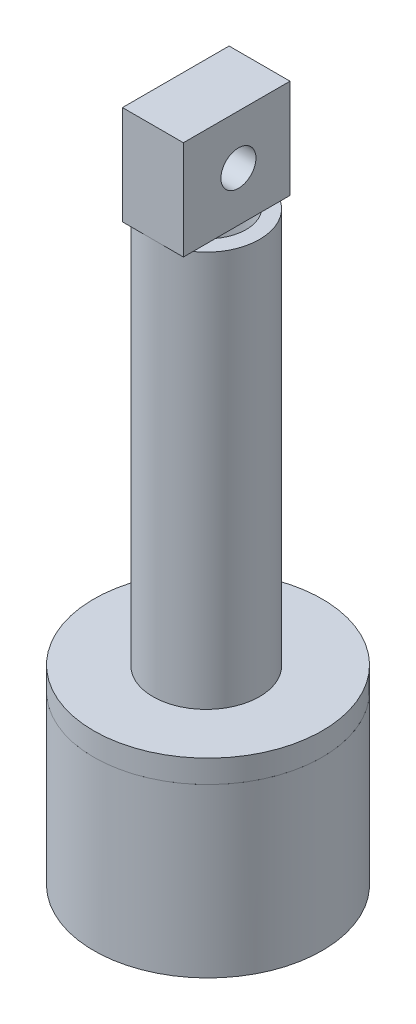
from build123d import *

# Parameters (mm, degrees)
SKETCH1_R           = 15
SKETCH1_R_2         = 12.5
BOSS_EXTRUDE1_DEPTH = 20
BOSS_EXTRUDE2_START = 2
SKETCH2_R           = 15
SKETCH2_R_2         = 11
BOSS_EXTRUDE2_DEPTH = 2
SKETCH4_R           = 15
BOSS_EXTRUDE3_DEPTH = 3
BOSS_EXTRUDE4_DEPTH = 4
SKETCH7_R           = 2.3
CUT_EXTRUDE1_DEPTH  = 10
SKETCH8_R           = 5
CUT_EXTRUDE2_DEPTH  = 10


with BuildPart() as part:
    # Sketch1 → Boss-Extrude1 (new body)
    with BuildSketch(Plane(origin=(0, 0, 0), x_dir=(1, 0, 0), z_dir=(0, 1, 0))):
        Circle(SKETCH1_R)
        Circle(SKETCH1_R_2, mode=Mode.SUBTRACT)
    extrude(amount=BOSS_EXTRUDE1_DEPTH)

    # Sketch2 → Boss-Extrude2 (add)
    with BuildSketch(Plane.XZ.offset(BOSS_EXTRUDE2_START)):
        Circle(SKETCH2_R)
        Circle(SKETCH2_R_2, mode=Mode.SUBTRACT)
    extrude(amount=-BOSS_EXTRUDE2_DEPTH)


with BuildPart() as body_2:
    # Sketch4 → Boss-Extrude3 (new body)
    with BuildSketch(Plane(origin=(0, 20, 0), x_dir=(1, 0, 0), z_dir=(0, 1, 0))):
        Circle(SKETCH4_R)
    extrude(amount=BOSS_EXTRUDE3_DEPTH)

    # Sketch5 → Revolve1 (revolve)
    with BuildSketch(Plane(origin=(0, 0, 0), x_dir=(0, 0, -1), z_dir=(1, 0, 0))):
        Polygon((6.769131535, 75), (-0.230868465, 75), (-0.230868465, 73), (4.769131535, 73), (4.769131535, 25), (-0.230868465, 25), (-0.230868465, 23), (6.769131535, 23), align=None)
    revolve(axis=Axis((0, 73, 0.230868465), (0, 1, 0)))

    # Sketch5_6 → Boss-Extrude4 (add, symmetric)
    with BuildSketch(Plane(origin=(0, 0, 0), x_dir=(0, 0, -1), z_dir=(1, 0, 0))):
        Polygon((-7.230868465, 88), (-7.230868465, 75), (-0.230868465, 75), (6.769131535, 75), (6.769131535, 88), align=None)
    extrude(amount=BOSS_EXTRUDE4_DEPTH, both=True)

    # Sketch7 → Cut-Extrude1 (cut)
    with BuildSketch(Plane(origin=(4, 0, 0), x_dir=(0, 0, -1), z_dir=(1, 0, 0))):
        with Locations((0, 81.5)):
            Circle(SKETCH7_R)
    extrude(amount=-CUT_EXTRUDE1_DEPTH, mode=Mode.SUBTRACT)

    # Sketch8 → Cut-Extrude2 (cut)
    with BuildSketch(Plane(origin=(0, 75, 0), x_dir=(1, 0, 0), z_dir=(0, 1, 0))):
        Circle(SKETCH8_R)
    extrude(amount=-CUT_EXTRUDE2_DEPTH, mode=Mode.SUBTRACT)


solid = Compound([part.part, body_2.part])
